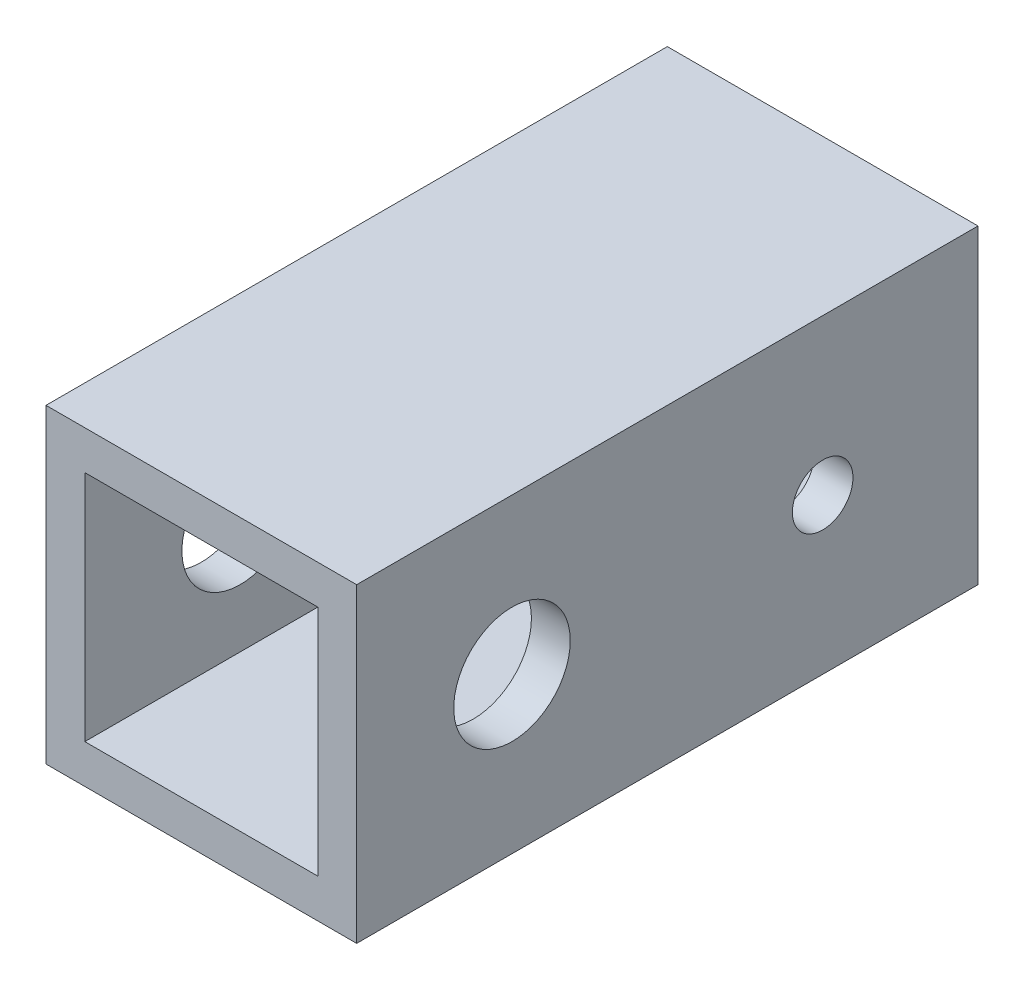
from build123d import *

# Parameters (mm, degrees)
SKETCH1_W           = 25.4
SKETCH1_H           = 25.4
SKETCH1_W_2         = 19.05
SKETCH1_H_2         = 19.05
EXTRUDE_THIN1_DEPTH = 50.8
SKETCH2_R           = 4.7625
SKETCH2_R_2         = 2.4765
CUT_EXTRUDE1_DEPTH  = 26.4


with BuildPart() as part:
    # Sketch1 → Extrude-Thin1 (new body)
    with BuildSketch(Plane.XY):
        Rectangle(SKETCH1_W, SKETCH1_H)
        Rectangle(SKETCH1_W_2, SKETCH1_H_2, mode=Mode.SUBTRACT)
    extrude(amount=EXTRUDE_THIN1_DEPTH)

    # Sketch2 → Cut-Extrude1 (cut, through all)
    with BuildSketch(Plane(origin=(12.7, 0, 0), x_dir=(0, 0, -1), z_dir=(1, 0, 0))):
        with Locations((-38.1, 0)):
            Circle(SKETCH2_R)
        with Locations((-12.7, 0)):
            Circle(SKETCH2_R_2)
    extrude(amount=-CUT_EXTRUDE1_DEPTH, mode=Mode.SUBTRACT)


solid = part.part
